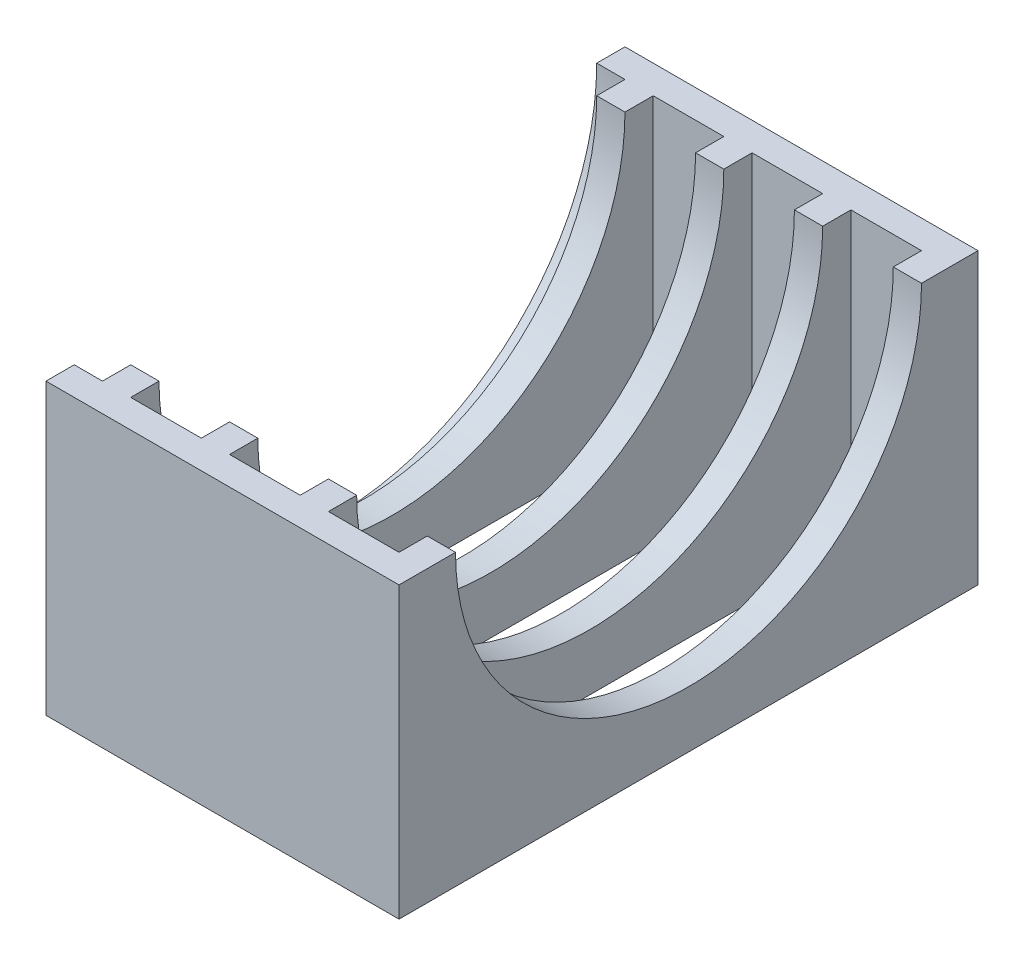
from build123d import *

# Parameters (mm, degrees)
SKETCH_1_W             = 25
SKETCH_1_H             = 41
EXTRUDE_415_DEPTH      = 2
SKETCH_5_W             = 25
SKETCH_5_H             = 2
EXTRUDE_624_DEPTH      = 18.5
SKETCH_7_W             = 4
SKETCH_7_H             = 37
SKETCH_7_W_2           = 2
EXTRUDE_1265_DEPTH     = 18.5
SKETCH_8_R             = 18.5
CUT_EXTRUDE_1405_DEPTH = 2
SKETCH_9_R             = 16.5
CUT_EXTRUDE_1536_DEPTH = 23
SKETCH_10_W            = 5
SKETCH_10_H            = 37
CUT_EXTRUDE_1762_DEPTH = 2


with BuildPart() as part:
    # 草图1 → Extrude 415 (new body)
    with BuildSketch(Plane(origin=(0, 0, 0), x_dir=(1, 0, 0), z_dir=(0, 1, 0))):
        with Locations((12.5, 20.5)):
            Rectangle(SKETCH_1_W, SKETCH_1_H)
    extrude(amount=EXTRUDE_415_DEPTH)

    # 草图5 → Extrude 624 (add)
    with BuildSketch(Plane(origin=(0, 2, 0), x_dir=(1, 0, 0), z_dir=(0, 1, 0))):
        with Locations((12.5, 40)):
            Rectangle(SKETCH_5_W, SKETCH_5_H)
        with Locations((12.5, 1)):
            Rectangle(SKETCH_5_W, SKETCH_5_H)
    extrude(amount=EXTRUDE_624_DEPTH)

    # 草图7 → Extrude 1265 (add)
    with BuildSketch(Plane(origin=(0, 2, 0), x_dir=(1, 0, 0), z_dir=(0, 1, 0))):
        with Locations((2, 20.5)):
            Rectangle(SKETCH_7_W, SKETCH_7_H)
        with Locations((10, 20.5)):
            Rectangle(SKETCH_7_W_2, SKETCH_7_H)
        with Locations((17, 20.5)):
            Rectangle(SKETCH_7_W_2, SKETCH_7_H)
        with Locations((24, 20.5)):
            Rectangle(SKETCH_7_W_2, SKETCH_7_H)
    extrude(amount=EXTRUDE_1265_DEPTH)

    # 草图8 → Cut-Extrude 1405 (cut)
    with BuildSketch(Plane.ZY):
        with Locations((-20.5, 20.5)):
            Circle(SKETCH_8_R)
    extrude(amount=-CUT_EXTRUDE_1405_DEPTH, mode=Mode.SUBTRACT)

    # 草图9 → Cut-Extrude 1536 (cut)
    with BuildSketch(Plane(origin=(25, 0, 0), x_dir=(0, 0, -1), z_dir=(1, 0, 0))):
        with Locations((20.5, 20.5)):
            Circle(SKETCH_9_R)
    extrude(amount=-CUT_EXTRUDE_1536_DEPTH, mode=Mode.SUBTRACT)

    # 草图10 → Cut-Extrude 1762 (cut)
    with BuildSketch(Plane(origin=(0, 2, 0), x_dir=(1, 0, 0), z_dir=(0, 1, 0))):
        with Locations((6.5, 20.5)):
            Rectangle(SKETCH_10_W, SKETCH_10_H)
        with Locations((13.5, 20.5)):
            Rectangle(SKETCH_10_W, SKETCH_10_H)
        with Locations((20.5, 20.5)):
            Rectangle(SKETCH_10_W, SKETCH_10_H)
    extrude(amount=-CUT_EXTRUDE_1762_DEPTH, mode=Mode.SUBTRACT)


solid = part.part
